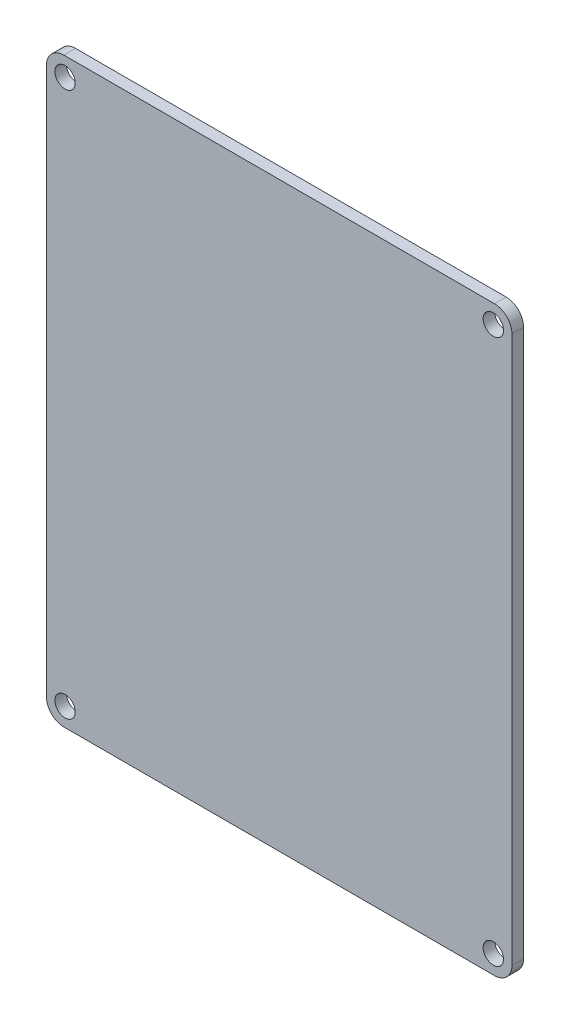
from build123d import *

# Parameters (mm, degrees)
EXTRUDE_1_DEPTH     = 2
CUT_EXTRUDE_1_DEPTH = 2


with BuildPart() as part:
    # 草图1 → 凸台-拉伸1 (new body)
    with BuildSketch(Plane.XY):
        with BuildLine():
            Line((-37, 50), (37, 50))
            ThreePointArc((37, 50), (39.121320344, 49.121320344), (40, 47))
            Line((40, 47), (40, -47))
            ThreePointArc((40, -47), (39.121320344, -49.121320344), (37, -50))
            Line((37, -50), (-37, -50))
            ThreePointArc((-37, -50), (-39.121320344, -49.121320344), (-40, -47))
            Line((-40, -47), (-40, 47))
            ThreePointArc((-40, 47), (-39.121320344, 49.121320344), (-37, 50))
        make_face()
    extrude(amount=-EXTRUDE_1_DEPTH)

    # 草图2 → 切除-拉伸1 (cut)
    with BuildSketch(Plane.XY):
        with BuildLine():
            ThreePointArc((-36.8, 48.55), (-38.037436867, 48.037436867), (-38.55, 46.8))
            Line((-38.55, 46.8), (-36.8, 46.8))
            Line((-36.8, 46.8), (-36.8, 48.55))
        make_face()
        with BuildLine():
            Line((-36.8, 46.8), (-38.55, 46.8))
            ThreePointArc((-38.55, 46.8), (-38.037436867, 45.562563133), (-36.8, 45.05))
            Line((-36.8, 45.05), (-36.8, 46.8))
        make_face()
        with BuildLine():
            Line((-36.8, 48.55), (-36.8, 46.8))
            Line((-36.8, 46.8), (-35.05, 46.8))
            ThreePointArc((-35.05, 46.8), (-35.562563133, 48.037436867), (-36.8, 48.55))
        make_face()
        with BuildLine():
            Line((-35.05, 46.8), (-36.8, 46.8))
            Line((-36.8, 46.8), (-36.8, 45.05))
            ThreePointArc((-36.8, 45.05), (-35.562563133, 45.562563133), (-35.05, 46.8))
        make_face()
        with BuildLine():
            ThreePointArc((-35.05, -46.8), (-35.562563133, -45.562563133), (-36.8, -45.05))
            Line((-36.8, -45.05), (-36.8, -46.8))
            Line((-36.8, -46.8), (-35.05, -46.8))
        make_face()
        with BuildLine():
            Line((-36.8, -46.8), (-36.8, -45.05))
            ThreePointArc((-36.8, -45.05), (-38.037436867, -45.562563133), (-38.55, -46.8))
            Line((-38.55, -46.8), (-36.8, -46.8))
        make_face()
        with BuildLine():
            Line((-36.8, -48.55), (-36.8, -46.8))
            Line((-36.8, -46.8), (-38.55, -46.8))
            ThreePointArc((-38.55, -46.8), (-38.037436867, -48.037436867), (-36.8, -48.55))
        make_face()
        with BuildLine():
            Line((-35.05, -46.8), (-36.8, -46.8))
            Line((-36.8, -46.8), (-36.8, -48.55))
            ThreePointArc((-36.8, -48.55), (-35.562563133, -48.037436867), (-35.05, -46.8))
        make_face()
        with BuildLine():
            ThreePointArc((36.8, -45.05), (35.562563133, -45.562563133), (35.05, -46.8))
            Line((35.05, -46.8), (36.8, -46.8))
            Line((36.8, -46.8), (36.8, -45.05))
        make_face()
        with BuildLine():
            Line((36.8, -46.8), (35.05, -46.8))
            ThreePointArc((35.05, -46.8), (35.562563133, -48.037436867), (36.8, -48.55))
            Line((36.8, -48.55), (36.8, -46.8))
        make_face()
        with BuildLine():
            ThreePointArc((38.55, -46.8), (38.037436867, -45.562563133), (36.8, -45.05))
            Line((36.8, -45.05), (36.8, -46.8))
            Line((36.8, -46.8), (38.55, -46.8))
        make_face()
        with BuildLine():
            Line((38.55, -46.8), (36.8, -46.8))
            Line((36.8, -46.8), (36.8, -48.55))
            ThreePointArc((36.8, -48.55), (38.037436867, -48.037436867), (38.55, -46.8))
        make_face()
        with BuildLine():
            ThreePointArc((36.8, 48.55), (35.562563133, 48.037436867), (35.05, 46.8))
            Line((35.05, 46.8), (36.8, 46.8))
            Line((36.8, 46.8), (36.8, 48.55))
        make_face()
        with BuildLine():
            Line((36.8, 46.8), (35.05, 46.8))
            ThreePointArc((35.05, 46.8), (35.562563133, 45.562563133), (36.8, 45.05))
            Line((36.8, 45.05), (36.8, 46.8))
        make_face()
        with BuildLine():
            Line((36.8, 48.55), (36.8, 46.8))
            Line((36.8, 46.8), (38.55, 46.8))
            ThreePointArc((38.55, 46.8), (38.037436867, 48.037436867), (36.8, 48.55))
        make_face()
        with BuildLine():
            Line((38.55, 46.8), (36.8, 46.8))
            Line((36.8, 46.8), (36.8, 45.05))
            ThreePointArc((36.8, 45.05), (38.037436867, 45.562563133), (38.55, 46.8))
        make_face()
    extrude(amount=-CUT_EXTRUDE_1_DEPTH, mode=Mode.SUBTRACT)


solid = part.part
